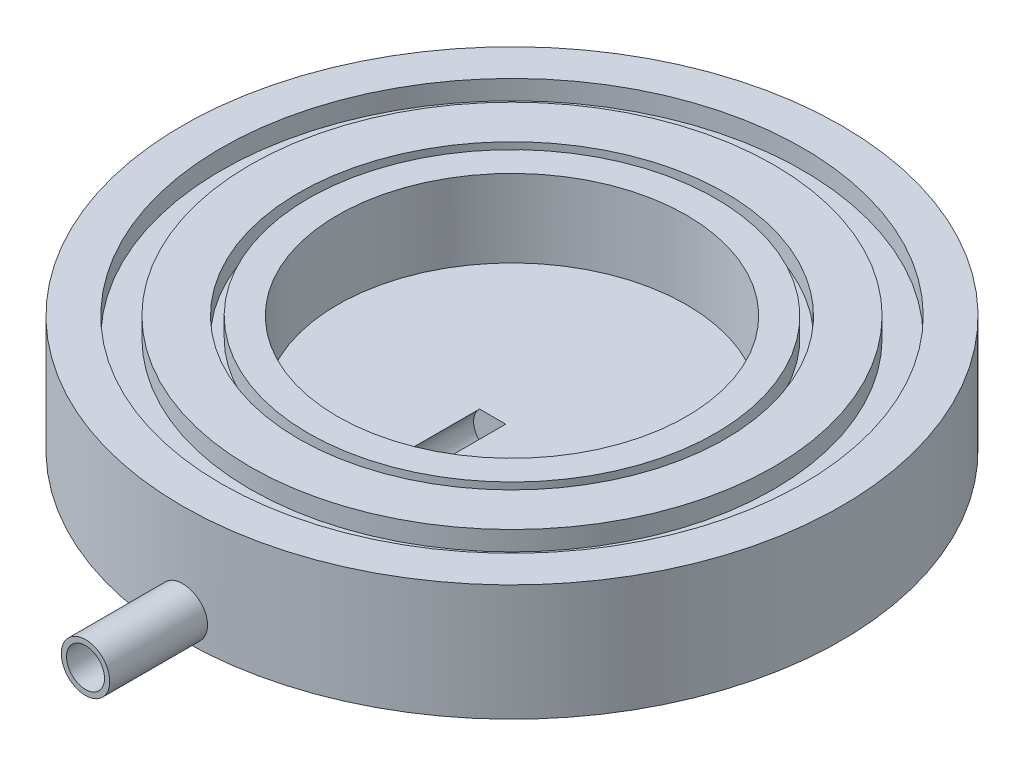
from build123d import *

# Parameters (mm, degrees)
SKETCH1_R           = 17
BOSS_EXTRUDE1_DEPTH = 6
SKETCH2_R           = 15
SKETCH2_R_2         = 13.5
CUT_EXTRUDE1_DEPTH  = 1
SKETCH3_R           = 11
SKETCH3_R_2         = 10.5
CUT_EXTRUDE2_DEPTH  = 1
SKETCH4_R           = 9
CUT_EXTRUDE3_DEPTH  = 4
SKETCH8_R           = 1.25
BOSS_EXTRUDE2_DEPTH = 22
SKETCH9_R           = 9
CUT_EXTRUDE5_DEPTH  = 4
SKETCH10_R          = 0.981301711
CUT_EXTRUDE6_DEPTH  = 21


with BuildPart() as part:
    # Sketch1 → Boss-Extrude1 (new body)
    with BuildSketch(Plane(origin=(0, 0, 0), x_dir=(1, 0, 0), z_dir=(0, 1, 0))):
        Circle(SKETCH1_R)
    extrude(amount=BOSS_EXTRUDE1_DEPTH)

    # Sketch2 → Cut-Extrude1 (cut)
    with BuildSketch(Plane(origin=(0, 6, 0), x_dir=(1, 0, 0), z_dir=(0, 1, 0))):
        Circle(SKETCH2_R)
        Circle(SKETCH2_R_2, mode=Mode.SUBTRACT)
    extrude(amount=-CUT_EXTRUDE1_DEPTH, mode=Mode.SUBTRACT)

    # Sketch3 → Cut-Extrude2 (cut)
    with BuildSketch(Plane(origin=(0, 6, 0), x_dir=(1, 0, 0), z_dir=(0, 1, 0))):
        Circle(SKETCH3_R)
        Circle(SKETCH3_R_2, mode=Mode.SUBTRACT)
    extrude(amount=-CUT_EXTRUDE2_DEPTH, mode=Mode.SUBTRACT)

    # Sketch4 → Cut-Extrude3 (cut)
    with BuildSketch(Plane(origin=(0, 6, 0), x_dir=(1, 0, 0), z_dir=(0, 1, 0))):
        Circle(SKETCH4_R)
    extrude(amount=-CUT_EXTRUDE3_DEPTH, mode=Mode.SUBTRACT)

    # Sketch8 → Boss-Extrude2 (add)
    with BuildSketch(Plane.XY):
        with Locations((0, 1.289022222)):
            Circle(SKETCH8_R)
    extrude(amount=BOSS_EXTRUDE2_DEPTH)

    # Sketch9 → Cut-Extrude5 (cut)
    with BuildSketch(Plane(origin=(0, 6, 0), x_dir=(1, 0, 0), z_dir=(0, 1, 0))):
        Circle(SKETCH9_R)
    extrude(amount=-CUT_EXTRUDE5_DEPTH, mode=Mode.SUBTRACT)

    # Sketch10 → Cut-Extrude6 (cut)
    with BuildSketch(Plane.XY.offset(22)):
        with Locations((0, 1.289022222)):
            Circle(SKETCH10_R)
    extrude(amount=-CUT_EXTRUDE6_DEPTH, mode=Mode.SUBTRACT)


solid = part.part
